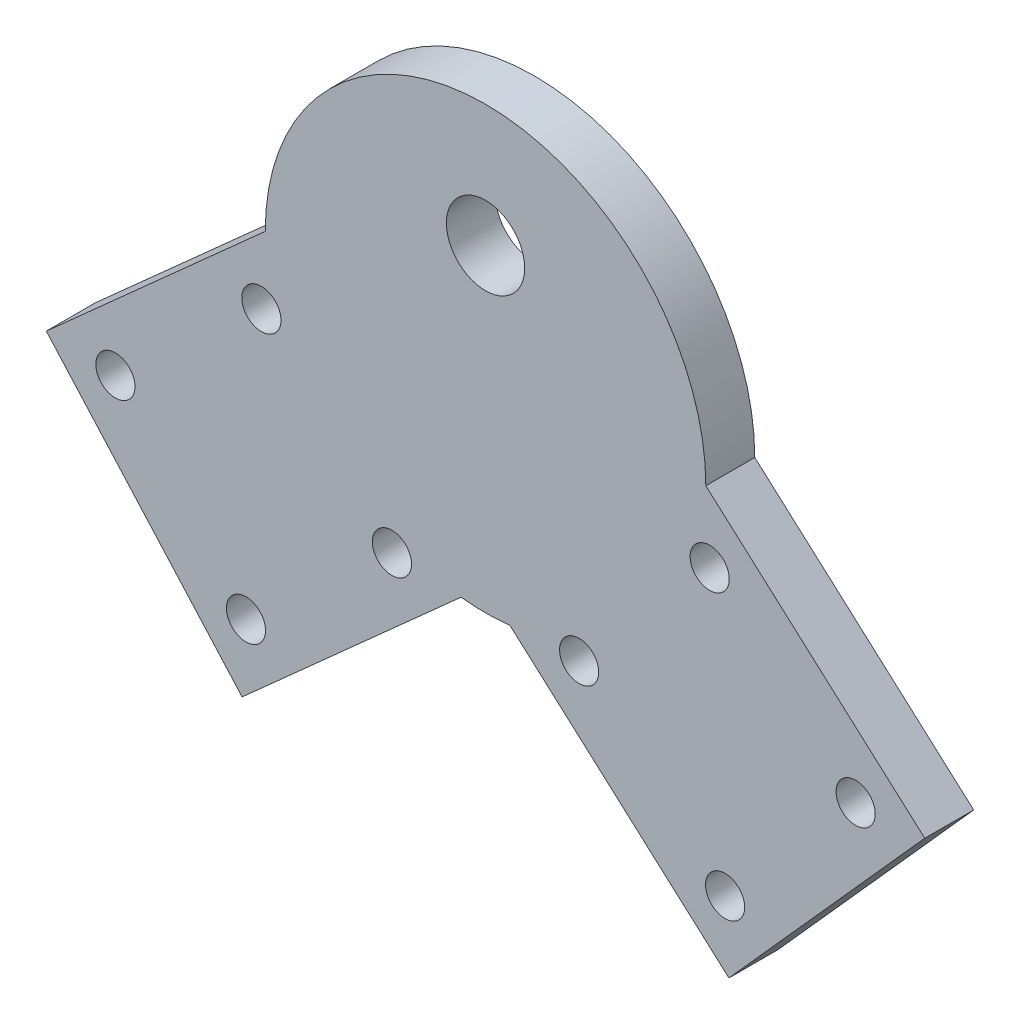
from build123d import *

# Parameters (mm, degrees)
SKETCH2_R           = 22.5
BOSS_EXTRUDE1_DEPTH = 5
SKETCH3_R           = 2
CUT_EXTRUDE1_DEPTH  = 5
SKETCH4_R           = 4
CUT_EXTRUDE2_DEPTH  = 10


with BuildPart() as part:
    # Sketch2 → Boss-Extrude1 (new body)
    with BuildSketch(Plane.XY):
        Circle(SKETCH2_R)
        Polygon((-22.5, 0), (-2.5, -22.360679775), (-24.860679775, -42.360679775), (-44.860679775, -20), align=None)
        Polygon((2.5, -22.360679775), (22.5, 0), (44.860679775, -20), (24.860679775, -42.360679775), align=None)
    extrude(amount=BOSS_EXTRUDE1_DEPTH)

    # Sketch3 → Cut-Extrude1 (cut)
    with BuildSketch(Plane(origin=(0, 0, 0), x_dir=(-1, 0, 0), z_dir=(0, 0, -1))):
        with Locations((-37.800566479, -20.393446629)):
            Circle(SKETCH3_R)
        with Locations((-22.893446629, -7.060113296)):
            Circle(SKETCH3_R)
        with Locations((-9.560113296, -21.967233146)):
            Circle(SKETCH3_R)
        with Locations((-24.467233146, -35.300566479)):
            Circle(SKETCH3_R)
        with Locations((24.467233146, -35.300566479)):
            Circle(SKETCH3_R)
        with Locations((37.800566479, -20.393446629)):
            Circle(SKETCH3_R)
        with Locations((9.560113296, -21.967233146)):
            Circle(SKETCH3_R)
        with Locations((22.893446629, -7.060113296)):
            Circle(SKETCH3_R)
    extrude(amount=-CUT_EXTRUDE1_DEPTH, mode=Mode.SUBTRACT)

    # Sketch4 → Cut-Extrude2 (cut)
    with BuildSketch(Plane(origin=(0, 0, 0), x_dir=(-1, 0, 0), z_dir=(0, 0, -1))):
        with Locations((0, 10)):
            Circle(SKETCH4_R)
    extrude(amount=-CUT_EXTRUDE2_DEPTH, mode=Mode.SUBTRACT)


solid = part.part
